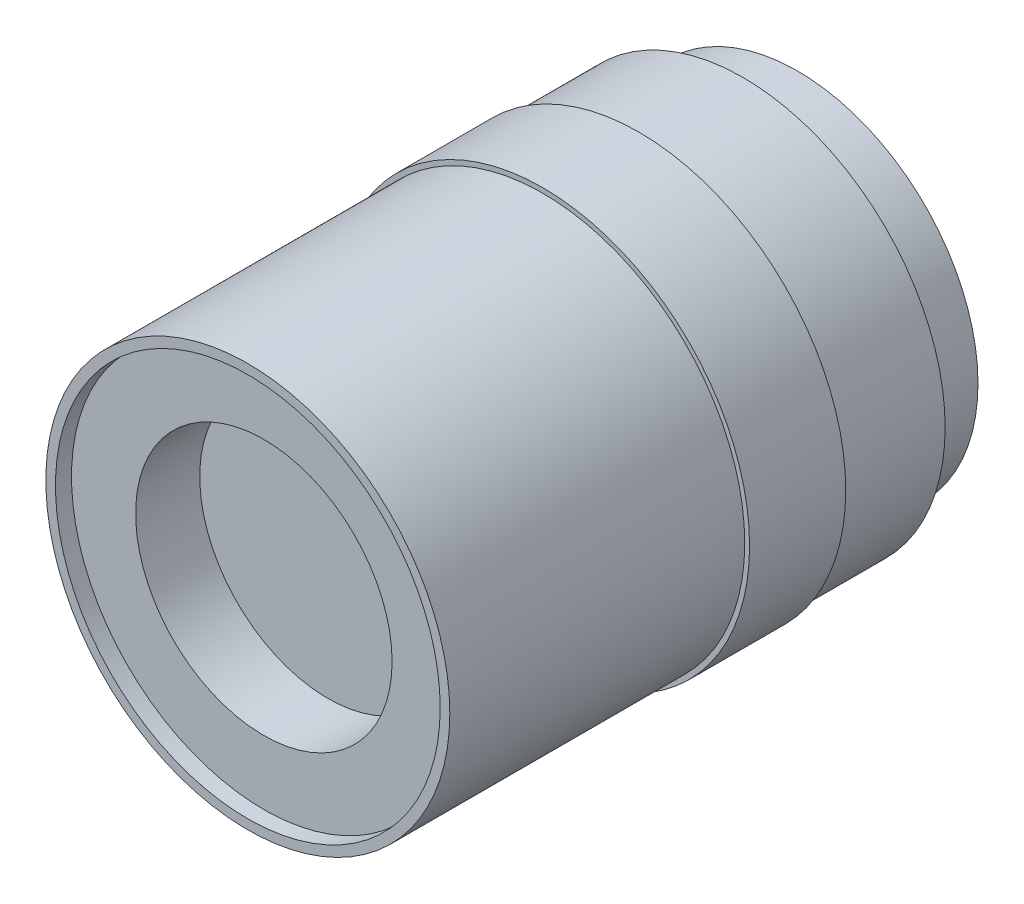
from build123d import *

# Parameters (mm, degrees)
SKETCH1_R          = 14.2875
EXTRUDE1_DEPTH     = 4.318
SKETCH2_R          = 16.002
EXTRUDE2_DEPTH     = 8.255
SKETCH3_R          = 16.383
EXTRUDE3_DEPTH     = 7.62
SKETCH4_R          = 16.002
EXTRUDE4_DEPTH     = 23.368
SKETCH5_R          = 15.24
CUT_EXTRUDE1_DEPTH = 1.27
SKETCH6_R          = 10.16
CUT_EXTRUDE2_DEPTH = 5.08


with BuildPart() as part:
    # Sketch1 → Extrude1 (new body)
    with BuildSketch(Plane.XY):
        Circle(SKETCH1_R)
    extrude(amount=EXTRUDE1_DEPTH)

    # Sketch2 → Extrude2 (add)
    with BuildSketch(Plane.XY.offset(4.318)):
        Circle(SKETCH2_R)
    extrude(amount=EXTRUDE2_DEPTH)

    # Sketch3 → Extrude3 (add)
    with BuildSketch(Plane.XY.offset(12.573)):
        Circle(SKETCH3_R)
    extrude(amount=EXTRUDE3_DEPTH)

    # Sketch4 → Extrude4 (add)
    with BuildSketch(Plane.XY.offset(20.193)):
        Circle(SKETCH4_R)
    extrude(amount=EXTRUDE4_DEPTH)

    # Sketch5 → Cut-Extrude1 (cut)
    with BuildSketch(Plane.XY.offset(43.561)):
        Circle(SKETCH5_R)
    extrude(amount=-CUT_EXTRUDE1_DEPTH, mode=Mode.SUBTRACT)

    # Sketch6 → Cut-Extrude2 (cut)
    with BuildSketch(Plane.XY.offset(42.291)):
        Circle(SKETCH6_R)
    extrude(amount=-CUT_EXTRUDE2_DEPTH, mode=Mode.SUBTRACT)


solid = part.part
